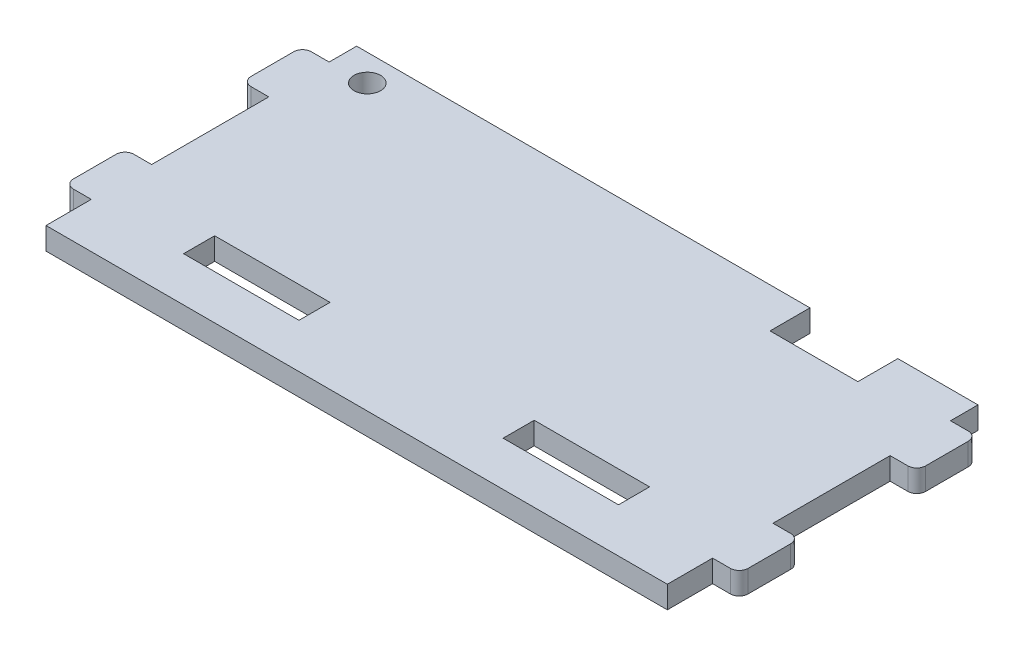
from build123d import *

# Parameters (mm, degrees)
SKETCH_1_W          = 76
SKETCH_1_H          = 35
EXTRUDE_1_DEPTH     = 2.5
SKETCH_2_W          = 13
SKETCH_2_H          = 3.5
CUT_EXTRUDE_1_DEPTH = 3.5
SKETCH_3_W          = 3
SKETCH_3_H          = 5.1
SKETCH_3_H_2        = 3.1
SKETCH_3_H_3        = 13.2
CUT_EXTRUDE_2_DEPTH = 3.5
FILLET_1_R          = 1
SKETCH_4_R          = 1.5
SKETCH_4_W          = 9.9
SKETCH_4_H          = 4.5
CUT_EXTRUDE_3_DEPTH = 3.5


with BuildPart() as part:
    # 草图1 → 凸台-拉伸1 (new body)
    with BuildSketch(Plane(origin=(0, 0, 0), x_dir=(1, 0, 0), z_dir=(0, 1, 0))):
        Rectangle(SKETCH_1_W, SKETCH_1_H)
    extrude(amount=EXTRUDE_1_DEPTH)

    # 草图2 → 切除-拉伸1 (cut, through all)
    with BuildSketch(Plane(origin=(0, 2.5, 0), x_dir=(1, 0, 0), z_dir=(0, 1, 0))):
        with Locations((-18, -10.75)):
            Rectangle(SKETCH_2_W, SKETCH_2_H)
        with Locations((18, -10.75)):
            Rectangle(SKETCH_2_W, SKETCH_2_H)
    extrude(amount=-CUT_EXTRUDE_1_DEPTH, mode=Mode.SUBTRACT)

    # 草图3 → 切除-拉伸2 (cut, through all)
    with BuildSketch(Plane(origin=(0, 2.5, 0), x_dir=(1, 0, 0), z_dir=(0, 1, 0))):
        with Locations((-36.5, -14.95)):
            Rectangle(SKETCH_3_W, SKETCH_3_H)
        with Locations((-36.5, 15.95)):
            Rectangle(SKETCH_3_W, SKETCH_3_H_2)
        with Locations((-36.5, 1)):
            Rectangle(SKETCH_3_W, SKETCH_3_H_3)
        with Locations((36.5, -14.95)):
            Rectangle(SKETCH_3_W, SKETCH_3_H)
        with Locations((36.5, 1)):
            Rectangle(SKETCH_3_W, SKETCH_3_H_3)
        with Locations((36.5, 15.95)):
            Rectangle(SKETCH_3_W, SKETCH_3_H_2)
    extrude(amount=-CUT_EXTRUDE_2_DEPTH, mode=Mode.SUBTRACT)

    # 圆角1
    fillet_1_edges = [part.edges().sort_by_distance(p)[0] for p in [
        (38, 1.25, -7.6),
        (38, 1.25, 5.6),
        (38, 1.25, -14.4),
        (-38, 1.25, 12.4),
        (-38, 1.25, -14.4),
        (-38, 1.25, 5.6),
        (-38, 1.25, -7.6),
        (38, 1.25, 12.4),
    ]]
    fillet(fillet_1_edges, radius=FILLET_1_R)

    # 草图4 → 切除-拉伸3 (cut, through all)
    with BuildSketch(Plane(origin=(0, 2.5, 0), x_dir=(1, 0, 0), z_dir=(0, 1, 0))):
        with Locations((-30.8, 14.5)):
            Circle(SKETCH_4_R)
        with Locations((21.018135054, 15.25)):
            Rectangle(SKETCH_4_W, SKETCH_4_H)
    extrude(amount=-CUT_EXTRUDE_3_DEPTH, mode=Mode.SUBTRACT)


solid = part.part
